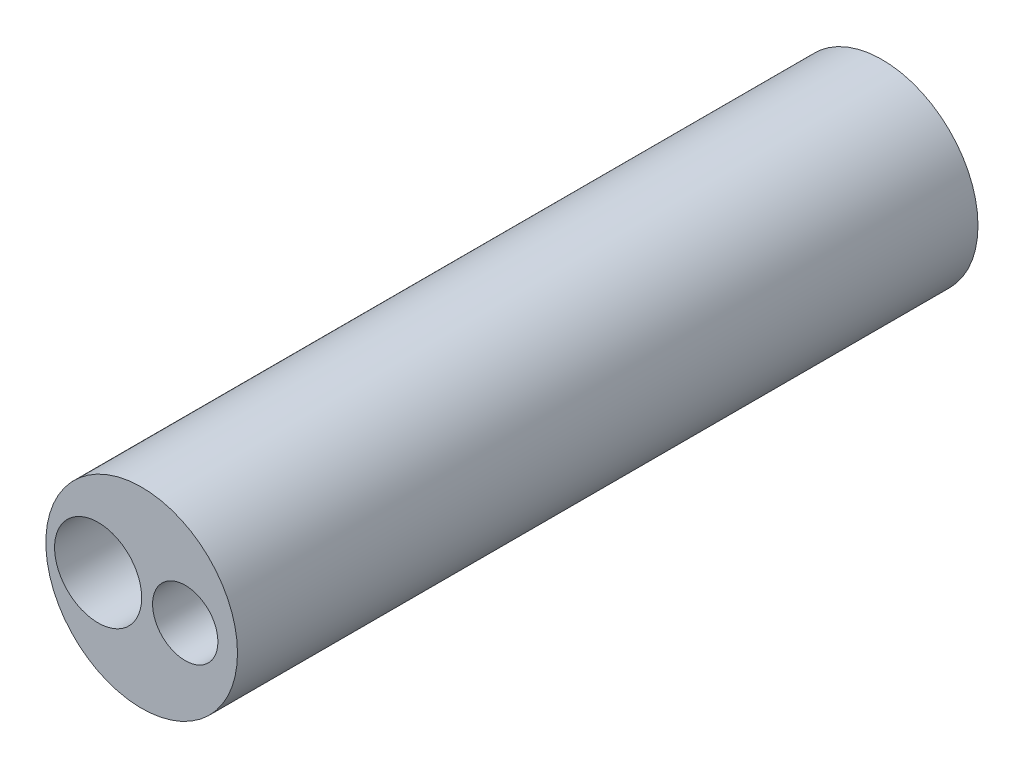
from build123d import *

# Parameters (mm, degrees)
SKETCH1_R           = 5.588
SKETCH1_R_2         = 5.08
BOSS_EXTRUDE1_DEPTH = 35.56
SKETCH2_R           = 5.588
SKETCH2_R_2         = 1.905
BOSS_EXTRUDE2_DEPTH = 7.62
SKETCH3_R           = 2.54
CUT_EXTRUDE1_DEPTH  = 33.02


with BuildPart() as part:
    # Sketch1 → Boss-Extrude1 (new body)
    with BuildSketch(Plane.XY):
        Circle(SKETCH1_R)
        Circle(SKETCH1_R_2, mode=Mode.SUBTRACT)
    extrude(amount=BOSS_EXTRUDE1_DEPTH)

    # Sketch2 → Boss-Extrude2 (add)
    with BuildSketch(Plane.XY.offset(35.56)):
        Circle(SKETCH2_R)
        with Locations((2.54, 0)):
            Circle(SKETCH2_R_2, mode=Mode.SUBTRACT)
    extrude(amount=BOSS_EXTRUDE2_DEPTH)

    # Sketch3 → Cut-Extrude1 (cut)
    with BuildSketch(Plane.XY.offset(43.18)):
        with Locations((-2.54, 0)):
            Circle(SKETCH3_R)
    extrude(amount=-CUT_EXTRUDE1_DEPTH, mode=Mode.SUBTRACT)


solid = part.part
